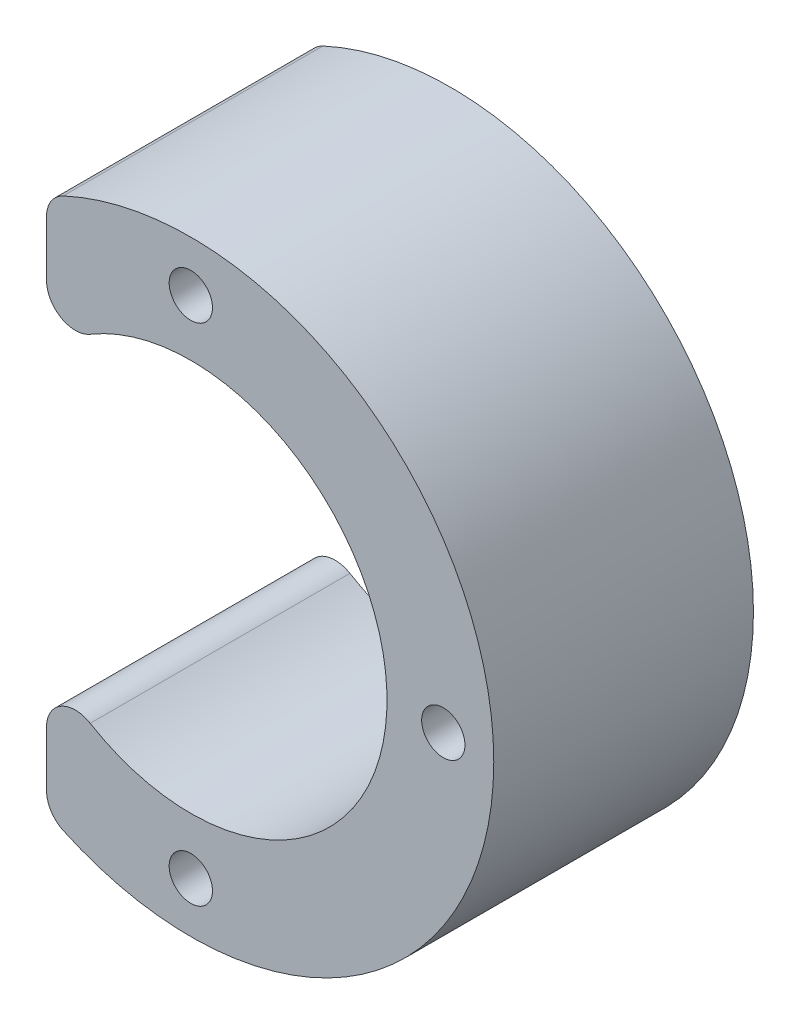
from build123d import *

# Parameters (mm, degrees)
SKETCH_1_R          = 21
EXTRUDE_1_DEPTH     = 18
SKETCH_2_R          = 1.5
SKETCH_2_R_2        = 13.6
CUT_EXTRUDE_1_DEPTH = 25
SKETCH_4_W          = 14.155551169
SKETCH_4_H          = 37.805917944
CUT_EXTRUDE_2_DEPTH = 25
FILLET_1_R          = 2


with BuildPart() as part:
    # 草图1 → 凸台-拉伸1 (new body)
    with BuildSketch(Plane.XY):
        Circle(SKETCH_1_R)
    extrude(amount=EXTRUDE_1_DEPTH)

    # 草图2 → 切除-拉伸1 (cut)
    with BuildSketch(Plane.XY.offset(18)):
        with Locations((-17.5, 0)):
            Circle(SKETCH_2_R)
        Circle(SKETCH_2_R_2)
        with Locations((0, 17.5)):
            Circle(SKETCH_2_R)
        with Locations((17.5, 0)):
            Circle(SKETCH_2_R)
        with Locations((0, -17.5)):
            Circle(SKETCH_2_R)
    extrude(amount=-CUT_EXTRUDE_1_DEPTH, mode=Mode.SUBTRACT)

    # 草图4 → 切除-拉伸2 (cut)
    with BuildSketch(Plane(origin=(0, 0, 0), x_dir=(-1, 0, 0), z_dir=(0, 0, -1))):
        with Locations((17.077775585, -0.436773659)):
            Rectangle(SKETCH_4_W, SKETCH_4_H)
    extrude(amount=-CUT_EXTRUDE_2_DEPTH, mode=Mode.SUBTRACT)

    # 圆角1
    fillet_1_edges = [part.edges().sort_by_distance(p)[0] for p in [
        (-10, -9.217374897, 9),
        (-10, 9.217374897, 9),
        (-10, -18.466185313, 9),
        (-10, 18.466185313, 9),
    ]]
    fillet(fillet_1_edges, radius=FILLET_1_R)


solid = part.part
